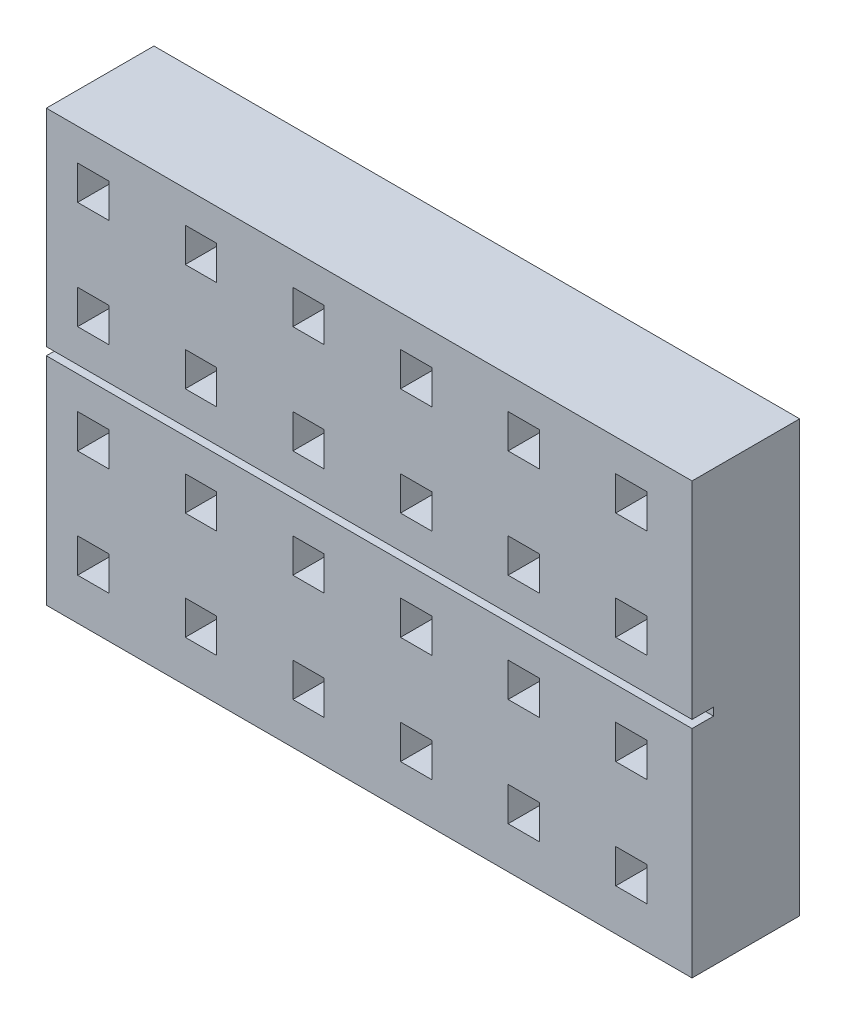
from build123d import *

# Parameters (mm, degrees)
SKETCH1_W           = 60
SKETCH1_H           = 40
BOSS_EXTRUDE1_DEPTH = 10
SKETCH2_W           = 2.909575839
SKETCH2_H           = 3.168204802
CUT_EXTRUDE1_DEPTH  = 10
SKETCH3_W           = 61.747665015
SKETCH3_H           = 0.72949372
CUT_EXTRUDE2_DEPTH  = 2


with BuildPart() as part:
    # Sketch1 → Boss-Extrude1 (new body)
    with BuildSketch(Plane.XY):
        with Locations((1.914893617, 6.489361702)):
            Rectangle(SKETCH1_W, SKETCH1_H)
    extrude(amount=BOSS_EXTRUDE1_DEPTH)

    # Sketch2 → Cut-Extrude1 (cut)
    with BuildSketch(Plane.XY.offset(10)):
        with Locations((-13.721702382, 21.942442266)):
            Rectangle(SKETCH2_W, SKETCH2_H)
        with Locations((-23.721702382, 21.942442266)):
            Rectangle(SKETCH2_W, SKETCH2_H)
        with Locations((-3.721702382, 21.942442266)):
            Rectangle(SKETCH2_W, SKETCH2_H)
        with Locations((6.278297618, 21.942442266)):
            Rectangle(SKETCH2_W, SKETCH2_H)
        with Locations((16.278297619, 21.942442266)):
            Rectangle(SKETCH2_W, SKETCH2_H)
        with Locations((26.278297619, 21.942442266)):
            Rectangle(SKETCH2_W, SKETCH2_H)
        with Locations((-13.721702382, 11.942442266)):
            Rectangle(SKETCH2_W, SKETCH2_H)
        with Locations((-3.721702382, 11.942442266)):
            Rectangle(SKETCH2_W, SKETCH2_H)
        with Locations((6.278297618, 11.942442266)):
            Rectangle(SKETCH2_W, SKETCH2_H)
        with Locations((16.278297619, 11.942442266)):
            Rectangle(SKETCH2_W, SKETCH2_H)
        with Locations((26.278297619, 11.942442266)):
            Rectangle(SKETCH2_W, SKETCH2_H)
        with Locations((-13.721702382, 1.942442266)):
            Rectangle(SKETCH2_W, SKETCH2_H)
        with Locations((-3.721702382, 1.942442266)):
            Rectangle(SKETCH2_W, SKETCH2_H)
        with Locations((6.278297618, 1.942442266)):
            Rectangle(SKETCH2_W, SKETCH2_H)
        with Locations((16.278297619, 1.942442266)):
            Rectangle(SKETCH2_W, SKETCH2_H)
        with Locations((26.278297619, 1.942442266)):
            Rectangle(SKETCH2_W, SKETCH2_H)
        with Locations((-13.721702382, -8.057557734)):
            Rectangle(SKETCH2_W, SKETCH2_H)
        with Locations((-3.721702382, -8.057557734)):
            Rectangle(SKETCH2_W, SKETCH2_H)
        with Locations((6.278297618, -8.057557734)):
            Rectangle(SKETCH2_W, SKETCH2_H)
        with Locations((16.278297619, -8.057557734)):
            Rectangle(SKETCH2_W, SKETCH2_H)
        with Locations((26.278297619, -8.057557734)):
            Rectangle(SKETCH2_W, SKETCH2_H)
        with Locations((-23.721702382, 11.942442266)):
            Rectangle(SKETCH2_W, SKETCH2_H)
        with Locations((-23.721702382, 1.942442266)):
            Rectangle(SKETCH2_W, SKETCH2_H)
        with Locations((-23.721702382, -8.057557734)):
            Rectangle(SKETCH2_W, SKETCH2_H)
    extrude(amount=-CUT_EXTRUDE1_DEPTH, mode=Mode.SUBTRACT)

    # Sketch3 → Cut-Extrude2 (cut)
    with BuildSketch(Plane.XY.offset(10)):
        with Locations((1.945695922, 6.927829606)):
            Rectangle(SKETCH3_W, SKETCH3_H)
    extrude(amount=-CUT_EXTRUDE2_DEPTH, mode=Mode.SUBTRACT)


solid = part.part
